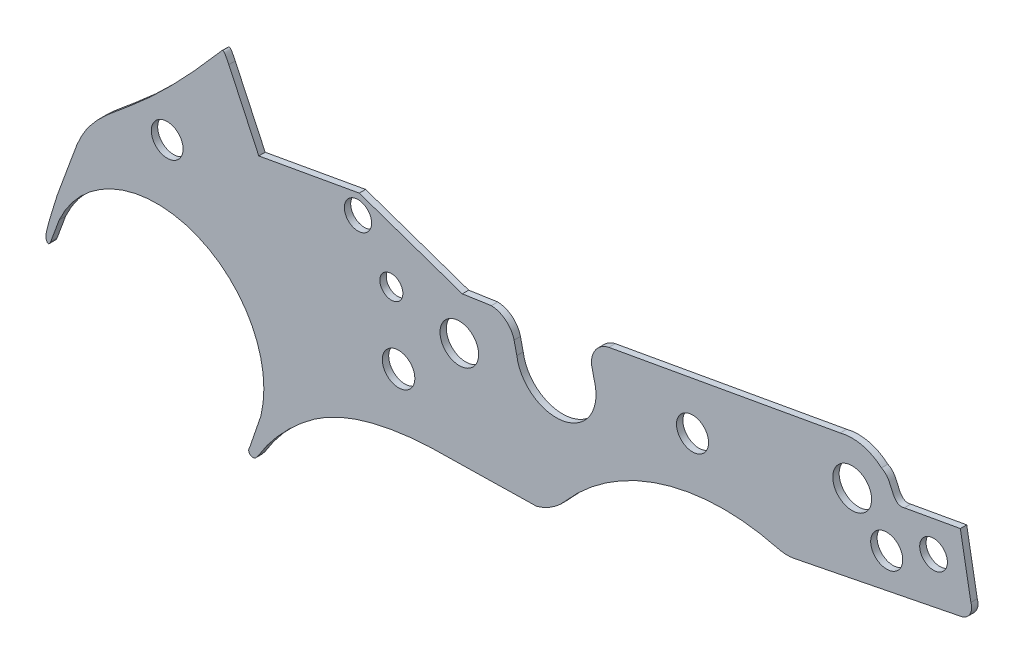
from build123d import *

# Parameters (mm, degrees)
ESBO_O1_R                = 24.856074233
ESBO_O1_R_2              = 25.406254871
ESBO_O1_R_3              = 30.184904221
ESBO_O1_R_4              = 21.338775915
ESBO_O1_R_5              = 17.98482722
ESBO_O1_R_6              = 25.023662551
ESBO_O1_R_7              = 30.348796638
ESBO_O1_R_8              = 25.055364887
ESBO_O1_R_9              = 21.645313363
RESSALTO_EXTRUS_O1_DEPTH = 10


with BuildPart() as part:
    # Esboço1 → Ressalto-extrusão1 (new body)
    with BuildSketch(Plane.XY):
        with BuildLine():
            Line((493.816315556, 444.358087538), (336.83712263, 416.175588715))
            Line((336.83712263, 416.175588715), (290.035490464, 516.368648598))
            add(Edge.make_bspline(
                [(290.035490464, 516.368648598), (287.712330769, 520.644643169), (285.709418986, 525.710802504), (281.265986128, 531.659576746), (279.052955354, 529.6907922)],
                knots=[0, 0, 0, 0, 0.704309023, 1, 1, 1, 1], degree=3))
            add(Edge.make_bspline(
                [(4.442704708, 137.565976398), (3.757198471, 144.910124968), (9.588977508, 165.574123425), (18.597342097, 197.409333874), (31.667816885, 232.560510285), (42.750119374, 261.921598081), (50.960331868, 286.175825056), (59.845234016, 305.160358554), (71.524226976, 324.368210545), (97.308336237, 353.035153395), (175.533966538, 412.912897239), (235.599895151, 479.180568341), (279.052955354, 529.6907922)],
                knots=[0, 0, 0, 0, 0.044405512, 0.129465835, 0.202697898, 0.272841244, 0.321071573, 0.358778673, 0.400527426, 0.457760414, 0.592733096, 1, 1, 1, 1], degree=3))
            add(Edge.make_bspline(
                [(11.668182442, 137.565976398), (7.674575408, 128.343869258), (4.442704708, 137.565976398)],
                knots=[0, 0, 0, 1, 1, 1], degree=2))
            Line((11.668182442, 137.565976398), (24.9746192, 173.65713897))
            ThreePointArc((24.9746192, 173.65713897), (231.505571154, 263.26360212), (340.200193886, 66.109268304))
            Line((340.200193886, 66.109268304), (322.368909592, 13.84531548))
            ThreePointArc((322.368909592, 13.84531548), (323.529108436, 4.841286631), (332.559115974, 5.778068762))
            Line((332.559115974, 5.778068762), (336.685811006, 10.990736171))
            add(Edge.make_bspline(
                [(602.857777914, 155.75104247), (546.585902339, 152.934744829), (464.371026278, 137.671583224), (381.497521998, 70.826880791), (350.387769673, 34.113841035), (336.685811006, 10.990736171)],
                knots=[0, 0, 0, 0, 0.54543399, 0.746227015, 1, 1, 1, 1], degree=3))
            Line((602.857777914, 155.75104247), (771.468146156, 159.046350592))
            ThreePointArc((771.468146156, 159.046350592), (795.969164257, 170.726749579), (816.144685284, 188.883840748))
            ThreePointArc((816.144685284, 188.883840748), (967.065190477, 287.035860841), (1147.056041634, 290.792379924))
            ThreePointArc((1147.056041634, 290.792379924), (1162.744905831, 288.74123251), (1178.445763781, 290.698456349))
            Line((1178.445763781, 290.698456349), (1432.051862487, 341.170454658))
            ThreePointArc((1432.051862487, 341.170454658), (1447.465281978, 350.447894498), (1449.685854759, 368.30044185))
            Line((1449.685854759, 368.30044185), (1433.211015372, 460.066860678))
            Line((1433.211015372, 460.066860678), (1345.711658236, 444.358087538))
            add(Edge.make_bspline(
                [(1310.002421381, 480.451349667), (1321.199976851, 475.017389977), (1324.559122984, 457.230439111), (1335.770629838, 441.594209845), (1345.711658236, 444.358087538)],
                knots=[0, 0, 0, 0, 0.588753132, 1, 1, 1, 1], degree=3))
            ThreePointArc((1310.002421381, 480.451349667), (1279.566897165, 496.121465608), (1245.338738742, 495.567535219))
            Line((1245.338738742, 495.567535219), (883.95058794, 430.687464526))
            ThreePointArc((883.95058794, 430.687464526), (863.497887041, 417.375021383), (856.802695037, 393.907841737))
            Line((856.802695037, 393.907841737), (861.016179461, 375.118258624))
            ThreePointArc((861.016179461, 375.118258624), (815.4395512, 295.859168797), (740.061153128, 347.602085877))
            Line((740.061153128, 347.602085877), (735.789693525, 366.378480162))
            ThreePointArc((735.789693525, 366.378480162), (722.850722659, 386.73241299), (700.294035725, 395.27029465))
            Line((700.294035725, 395.27029465), (654.935405487, 388.555003202))
            Line((654.935405487, 388.555003202), (493.816315556, 444.358087538))
        make_face()
        with Locations((193.698270161, 366.314181508)):
            Circle(ESBO_O1_R, mode=Mode.SUBTRACT)
        with Locations((555.280371961, 237.017321532)):
            Circle(ESBO_O1_R_2, mode=Mode.SUBTRACT)
        with Locations((650.213694883, 319.217363287)):
            Circle(ESBO_O1_R_3, mode=Mode.SUBTRACT)
        with Locations((491.842444827, 413.29978542)):
            Circle(ESBO_O1_R_4, mode=Mode.SUBTRACT)
        with Locations((543.993369584, 342.564707931)):
            Circle(ESBO_O1_R_5, mode=Mode.SUBTRACT)
        with Locations((1014.650016096, 379.499591773)):
            Circle(ESBO_O1_R_6, mode=Mode.SUBTRACT)
        with Locations((1264.148093295, 430.129268588)):
            Circle(ESBO_O1_R_7, mode=Mode.SUBTRACT)
        with Locations((1318.126095233, 372.579227821)):
            Circle(ESBO_O1_R_8, mode=Mode.SUBTRACT)
        with Locations((1391.309727217, 404.333963321)):
            Circle(ESBO_O1_R_9, mode=Mode.SUBTRACT)
    extrude(amount=RESSALTO_EXTRUS_O1_DEPTH)


solid = part.part
